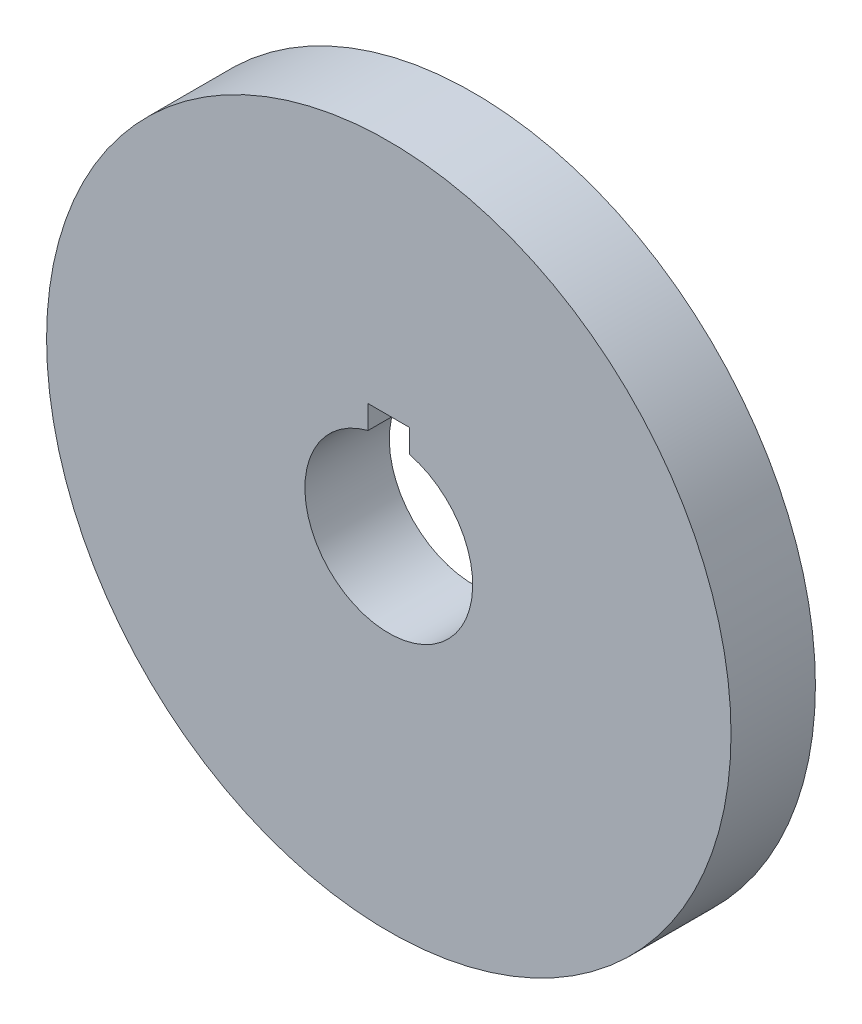
from build123d import *

# Parameters (mm, degrees)
SKETCH1_R           = 25.75
BOSS_EXTRUDE1_DEPTH = 6.35


with BuildPart() as part:
    # Sketch1 → Boss-Extrude1 (new body)
    with BuildSketch(Plane.XY):
        Circle(SKETCH1_R)
        with BuildLine():
            Line((-1.5625, 7.875), (1.5625, 7.875))
            Line((1.5625, 7.875), (1.5625, 6.116064911))
            ThreePointArc((1.5625, 6.116064911), (0, -6.3125), (-1.5625, 6.116064911))
            Line((-1.5625, 6.116064911), (-1.5625, 7.875))
        make_face(mode=Mode.SUBTRACT)
    extrude(amount=BOSS_EXTRUDE1_DEPTH)


solid = part.part
